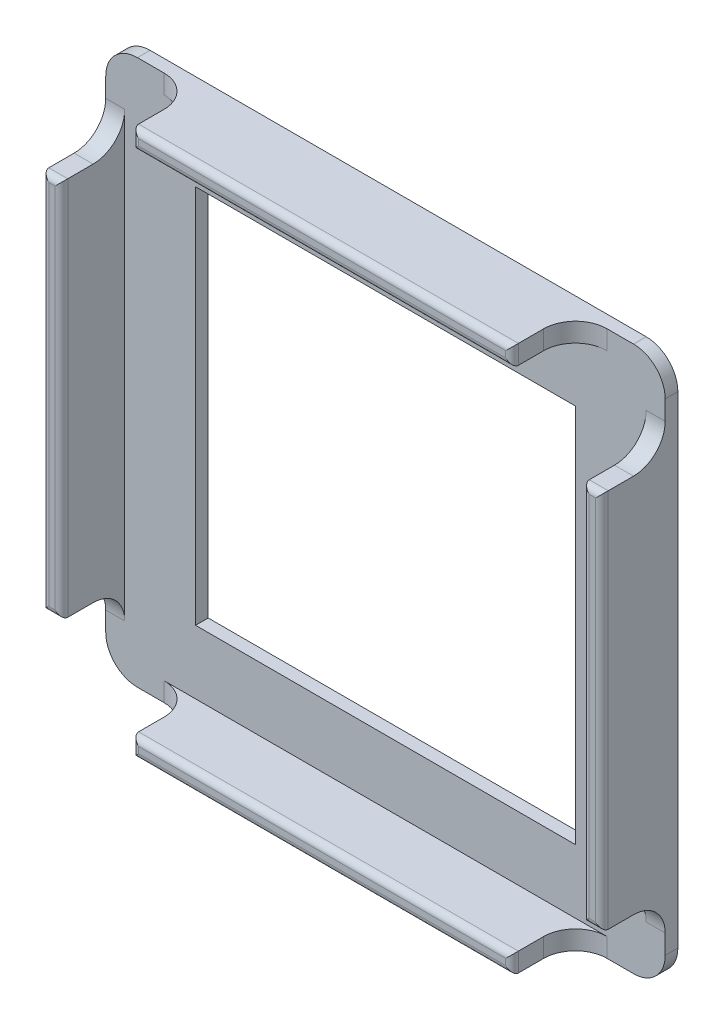
from build123d import *

# Parameters (mm, degrees)
SKETCH1_W           = 88.3722
SKETCH1_H           = 86.137
BOSS_EXTRUDE1_DEPTH = 2
SKETCH2_W           = 3
SKETCH2_H           = 60
SKETCH2_W_2         = 60
SKETCH2_H_2         = 3
BOSS_EXTRUDE2_DEPTH = 10
FILLET1_R           = 5
FILLET2_R           = 5
FILLET3_R           = 1
CUT_EXTRUDE1_REACH  = 4
SKETCH3_W           = 60
SKETCH3_H           = 60


with BuildPart() as part:
    # Sketch1 → Boss-Extrude1 (new body)
    with BuildSketch(Plane.XY):
        with Locations((44.1861, 43.0685)):
            Rectangle(SKETCH1_W, SKETCH1_H)
    extrude(amount=BOSS_EXTRUDE1_DEPTH)

    # Sketch2 → Boss-Extrude2 (add)
    with BuildSketch(Plane.XY.offset(2)):
        with Locations((1.5, 43.0685)):
            Rectangle(SKETCH2_W, SKETCH2_H)
        with Locations((86.8722, 43.0685)):
            Rectangle(SKETCH2_W, SKETCH2_H)
        with Locations((44.1861, 1.5)):
            Rectangle(SKETCH2_W_2, SKETCH2_H_2)
        with Locations((44.1861, 84.637)):
            Rectangle(SKETCH2_W_2, SKETCH2_H_2)
    extrude(amount=BOSS_EXTRUDE2_DEPTH)

    # Fillet1
    fillet1_edges = [part.edges().sort_by_distance(p)[0] for p in [
        (0, 86.137, 1),
        (88.3722, 86.137, 1),
        (88.3722, 0, 1),
        (0, 0, 1),
    ]]
    fillet(fillet1_edges, radius=FILLET1_R)

    # Fillet2
    fillet2_edges = [part.edges().sort_by_distance(p)[0] for p in [
        (1.5, 13.0685, 2),
        (1.5, 73.0685, 2),
        (86.8722, 73.0685, 2),
        (86.8722, 13.0685, 2),
        (14.1861, 84.637, 2),
        (74.1861, 84.637, 2),
        (74.1861, 1.5, 2),
        (14.1861, 1.5, 2),
    ]]
    fillet(fillet2_edges, radius=FILLET2_R)

    # Fillet3
    fillet3_edges = [part.edges().sort_by_distance(p)[0] for p in [
        (0, 43.0685, 12),
        (1.5, 13.0685, 12),
        (3, 43.0685, 12),
        (1.5, 73.0685, 12),
        (88.3722, 43.0685, 12),
        (86.8722, 73.0685, 12),
        (85.3722, 43.0685, 12),
        (86.8722, 13.0685, 12),
        (14.1861, 84.637, 12),
        (44.1861, 83.137, 12),
        (74.1861, 84.637, 12),
        (44.1861, 86.137, 12),
        (44.1861, 0, 12),
        (74.1861, 1.5, 12),
        (44.1861, 3, 12),
        (14.1861, 1.5, 12),
    ]]
    fillet(fillet3_edges, radius=FILLET3_R)

    # Sketch3 → Cut-Extrude1 (cut, up to next)
    with BuildSketch(Plane.XY.offset(2), mode=Mode.PRIVATE) as cut_extrude1_sk1:
        with Locations((44.1861, 43.0685)):
            Rectangle(SKETCH3_W, SKETCH3_H)
    cut_extrude1_tool1 = extrude(cut_extrude1_sk1.sketch, amount=-CUT_EXTRUDE1_REACH, mode=Mode.PRIVATE) & part.part
    add(cut_extrude1_tool1.solids().sort_by_distance((44.1861, 43.0685, 2))[0], mode=Mode.SUBTRACT)


solid = part.part
